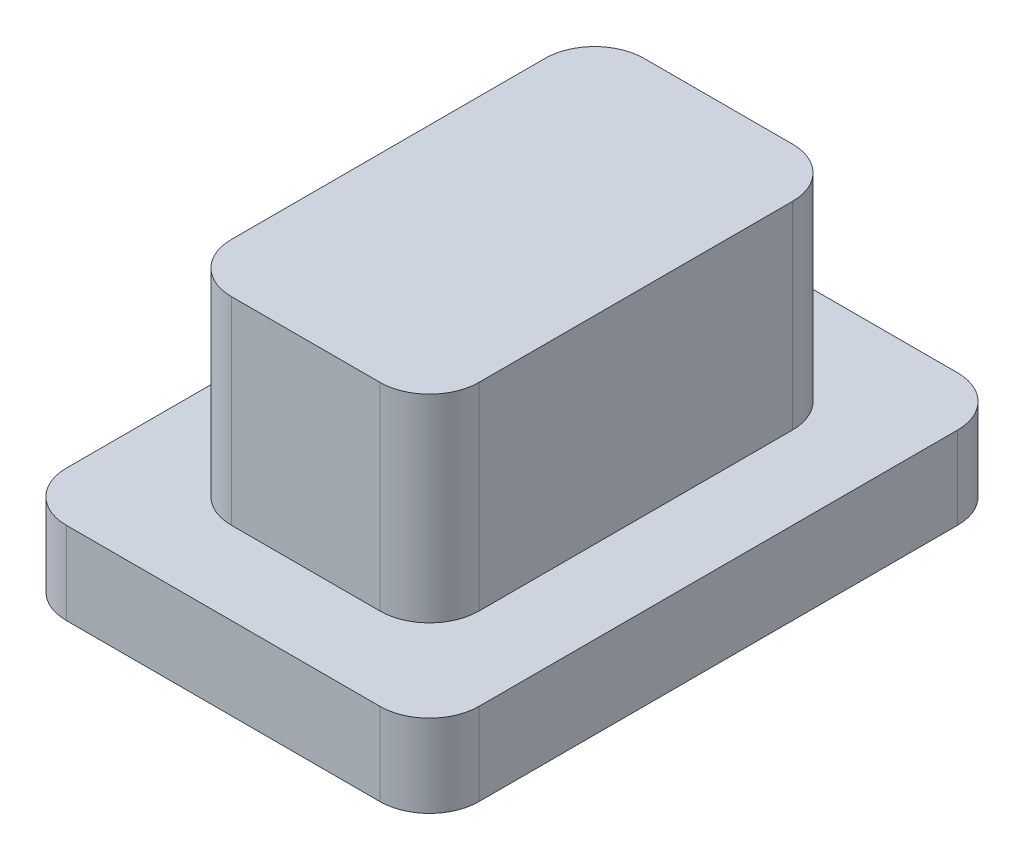
from build123d import *

# Parameters (mm, degrees)
SKETCH_1_W      = 5
SKETCH_1_H      = 7
EXTRUDE_1_DEPTH = 1
SKETCH_2_W      = 3
SKETCH_2_H      = 5
EXTRUDE_2_DEPTH = 2.4
FILLET_1_R      = 0.6


with BuildPart() as part:
    # 草图1 → 凸台-拉伸1 (new body)
    with BuildSketch(Plane(origin=(0, 0, 0), x_dir=(1, 0, 0), z_dir=(0, 1, 0))):
        Rectangle(SKETCH_1_W, SKETCH_1_H)
    extrude(amount=EXTRUDE_1_DEPTH)

    # 草图2 → 凸台-拉伸2 (add)
    with BuildSketch(Plane(origin=(0, 1, 0), x_dir=(1, 0, 0), z_dir=(0, 1, 0))):
        Rectangle(SKETCH_2_W, SKETCH_2_H)
    extrude(amount=EXTRUDE_2_DEPTH)

    # 圆角1
    fillet_1_edges = [part.edges().sort_by_distance(p)[0] for p in [
        (1.5, 2.2, 2.5),
        (1.5, 2.2, -2.5),
        (-1.5, 2.2, -2.5),
        (-1.5, 2.2, 2.5),
        (2.5, 0.5, 3.5),
        (-2.5, 0.5, 3.5),
        (-2.5, 0.5, -3.5),
        (2.5, 0.5, -3.5),
    ]]
    fillet(fillet_1_edges, radius=FILLET_1_R)


solid = part.part
